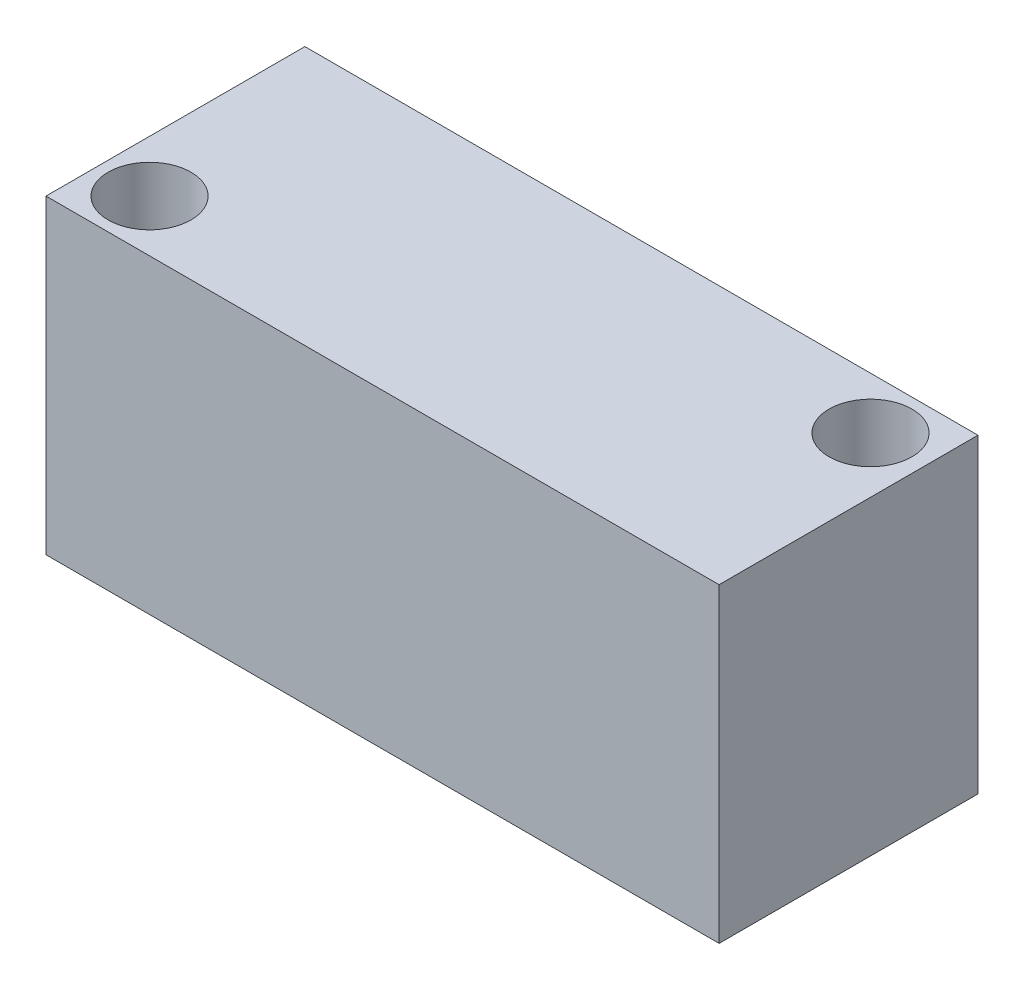
from build123d import *

# Parameters (mm, degrees)
SKETCH1_W           = 65
SKETCH1_H           = 25
SKETCH1_R           = 4
BOSS_EXTRUDE1_DEPTH = 30


with BuildPart() as part:
    # Sketch1 → Boss-Extrude1 (new body)
    with BuildSketch(Plane(origin=(0, 0, 0), x_dir=(1, 0, 0), z_dir=(0, 1, 0))):
        with Locations((64.814608674, -11.186863063)):
            Rectangle(SKETCH1_W, SKETCH1_H)
        with Locations((37.314608674, -18.686863063)):
            Circle(SKETCH1_R, mode=Mode.SUBTRACT)
        with Locations((91.934350197, -3.686863063)):
            Circle(SKETCH1_R, mode=Mode.SUBTRACT)
    extrude(amount=BOSS_EXTRUDE1_DEPTH)


solid = part.part
